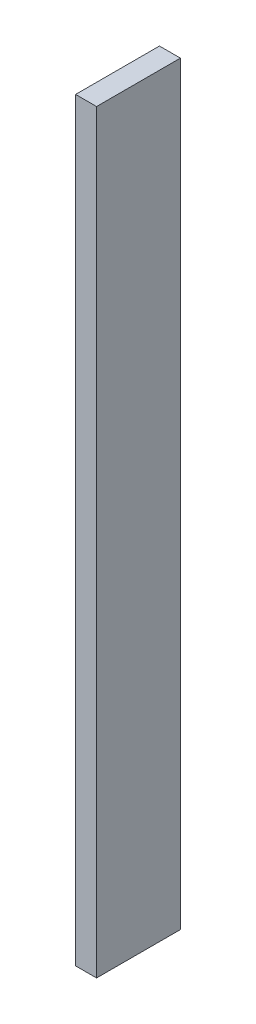
from build123d import *

# Parameters (mm, degrees)
SKETCH1_W           = 12.7
SKETCH1_H           = 50.8
BOSS_EXTRUDE1_DEPTH = 457.2


with BuildPart() as part:
    # Sketch1 → Boss-Extrude1 (new body)
    with BuildSketch(Plane(origin=(0, 0, 0), x_dir=(1, 0, 0), z_dir=(0, 1, 0))):
        with Locations((6.35, 25.4)):
            Rectangle(SKETCH1_W, SKETCH1_H)
    extrude(amount=-BOSS_EXTRUDE1_DEPTH)


solid = part.part
